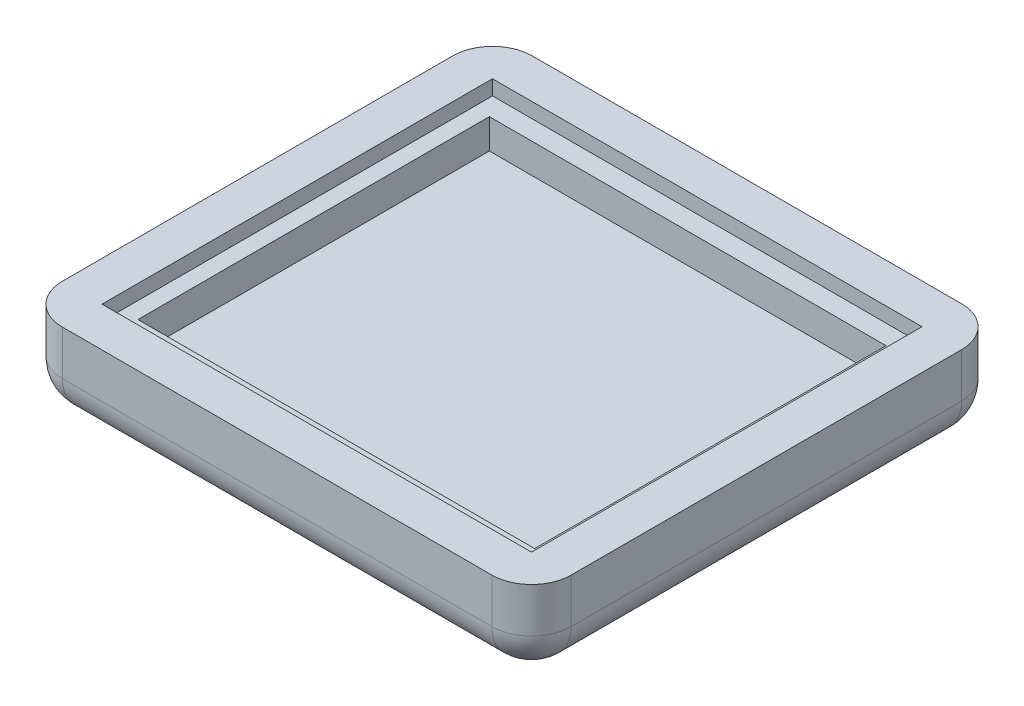
from build123d import *

# Parameters (mm, degrees)
SKETCH1_W           = 5.08
SKETCH1_H           = 5.08
BOSS_EXTRUDE1_DEPTH = 5.715
SKETCH2_W           = 65.16
SKETCH2_H           = 60.16
BOSS_EXTRUDE2_DEPTH = 5.08
FILLET1_R           = 5.08
SKETCH3_W           = 55
SKETCH3_H           = 50
BOSS_EXTRUDE3_DEPTH = 3.81
CUT_EXTRUDE1_DEPTH  = 3.81


with BuildPart() as part:
    # Sketch1 → Boss-Extrude1 (new body)
    with BuildSketch(Plane(origin=(0, 0, 0), x_dir=(1, 0, 0), z_dir=(0, 1, 0))):
        Polygon((-5.08, 0), (0, 0), (0, 50), (55, 50), (55, 55.08), (-5.08, 55.08), align=None)
        Polygon((55, 0), (0, 0), (0, -5.08), (60.08, -5.08), (60.08, 50), (55, 50), align=None)
        with Locations((-2.54, -2.54)):
            Rectangle(SKETCH1_W, SKETCH1_H)
        with Locations((57.54, 52.54)):
            Rectangle(SKETCH1_W, SKETCH1_H)
    extrude(amount=-BOSS_EXTRUDE1_DEPTH)

    # Sketch2 → Boss-Extrude2 (add)
    with BuildSketch(Plane(origin=(0, -5.715, 0), x_dir=(-1, 0, 0), z_dir=(0, -1, 0))):
        with Locations((-27.5, 25)):
            Rectangle(SKETCH2_W, SKETCH2_H)
    extrude(amount=BOSS_EXTRUDE2_DEPTH)

    # Fillet1
    fillet1_edges = [part.edges().sort_by_distance(p)[0] for p in [
        (-5.08, -5.3975, 5.08),
        (-5.08, -5.3975, -55.08),
        (60.08, -5.3975, -55.08),
        (60.08, -5.3975, 5.08),
        (-5.08, -10.795, -25),
        (27.5, -10.795, -55.08),
        (60.08, -10.795, -25),
        (27.5, -10.795, 5.08),
    ]]
    fillet(fillet1_edges, radius=FILLET1_R)

    # Sketch3 → Boss-Extrude3 (add)
    with BuildSketch(Plane(origin=(0, -5.715, 0), x_dir=(1, 0, 0), z_dir=(0, 1, 0))):
        with Locations((27.5, 25)):
            Rectangle(SKETCH3_W, SKETCH3_H)
    extrude(amount=BOSS_EXTRUDE3_DEPTH)

    # Sketch4 → Cut-Extrude1 (cut)
    with BuildSketch(Plane(origin=(0, -1.905, 0), x_dir=(1, 0, 0), z_dir=(0, 1, 0))):
        Polygon((27.5, 25), (52.25, 47.5), (2.75, 47.5), align=None)
        Polygon((52.9, 47.5), (52.25, 47.5), (27.5, 25), (52.25, 2.5), (52.9, 2.5), align=None)
        Polygon((52.25, 2.5), (27.5, 25), (2.75, 2.5), align=None)
        Polygon((2.75, 2.5), (27.5, 25), (2.75, 47.5), (2.1, 47.5), (2.1, 2.5), align=None)
    extrude(amount=-CUT_EXTRUDE1_DEPTH, mode=Mode.SUBTRACT)


solid = part.part
